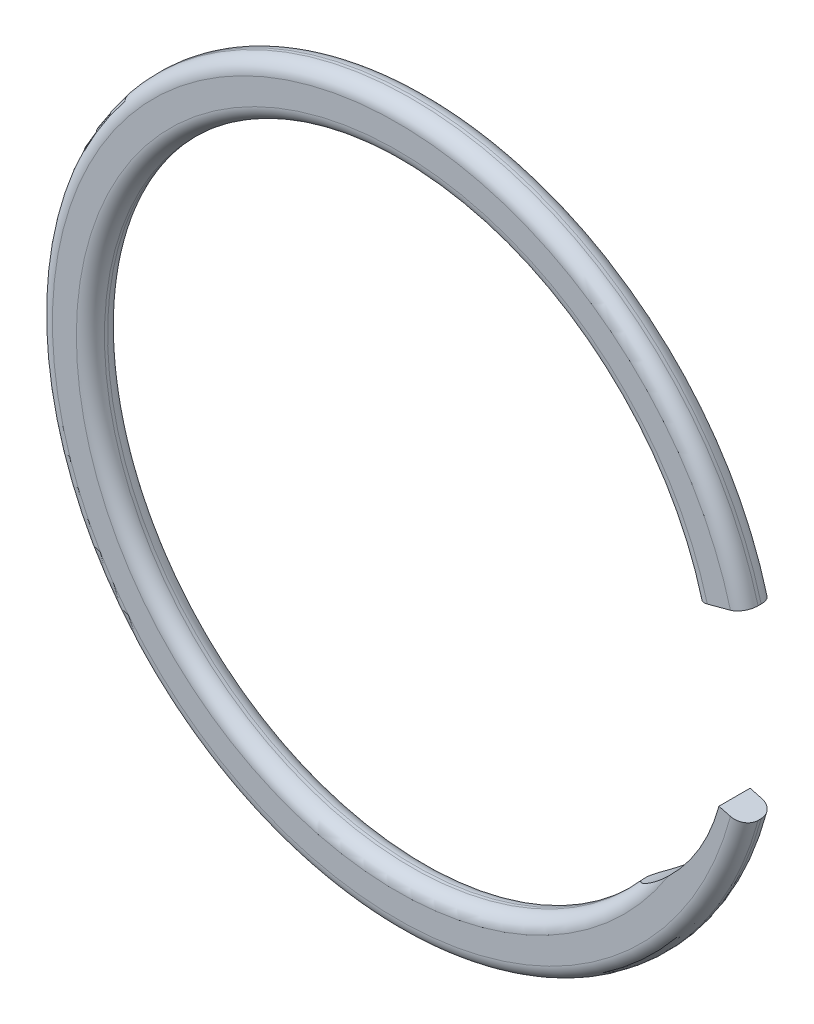
from build123d import *

# Parameters (mm, degrees)
EXTRUDE1_DEPTH = 0.15239999999999998
FILLET1_R      = 0.13716


with BuildPart() as part:
    # Sketch2 → Extrude1 (new, symmetric)
    with BuildSketch(Plane.XY):
        with BuildLine():
            Line((3.140418046431012, -0.8414724794373154), (3.3857632063084426, -0.9072125168933589))
            ThreePointArc((3.3857632063084426, -0.9072125168933589), (-3.505200000000001, 4.3e-16), (3.3857632063084426, 0.9072125168933589))
            Line((3.3857632063084426, 0.9072125168933589), (2.895072886553593, 0.7757324419812774))
            ThreePointArc((2.895072886553593, 0.7757324419812774), (-2.920866106263664, 0.6721227784267793), (2.2648416082243603, -1.9630843918832563))
            ThreePointArc((2.2648416082243603, -1.9630843918832563), (2.81661020018612, -1.4912562075486206), (3.140418046431012, -0.8414724794373154))
        make_face()
    extrude(amount=EXTRUDE1_DEPTH, both=True)

    # Fillet1
    fillet1_edges = [part.edges().sort_by_distance(p)[0] for p in [
        (-3.5052000000000008, 2.55e-15, 0.15239999999999998),
        (-2.920866106263662, 0.6721227784267882, 0.15239999999999998),
        (-3.5052000000000008, 2.55e-15, -0.15239999999999998),
        (-2.920866106263662, 0.6721227784267882, -0.15239999999999998),
    ]]
    fillet(fillet1_edges, radius=FILLET1_R)


solid = part.part
